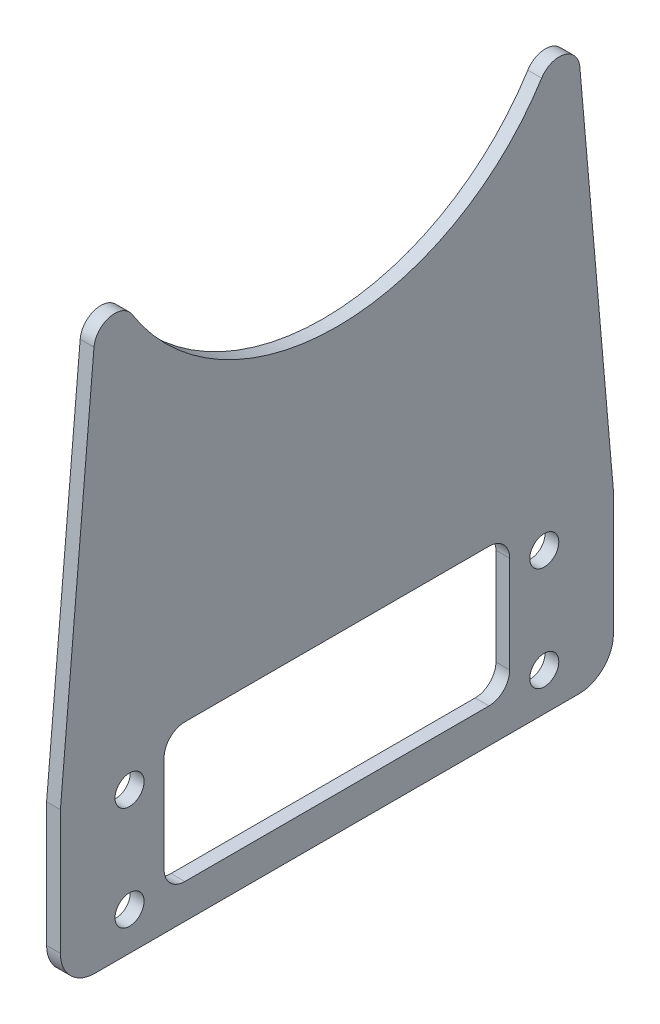
from build123d import *

# Parameters (mm, degrees)
EXTRUDE_1_DEPTH     = 2
SKETCH_2_R          = 2.1
SKETCH_2_W          = 50
SKETCH_2_H          = 20
CUT_EXTRUDE_1_DEPTH = 2
FILLET_1_R          = 3
FILLET_2_R          = 5


with BuildPart() as part:
    # 草图1 → 凸台-拉伸1 (new body)
    with BuildSketch(Plane(origin=(0, 0, 0), x_dir=(0, 0, -1), z_dir=(1, 0, 0))):
        with BuildLine():
            Line((-40, 11.5), (-34.088778562, 79.065570207))
            ThreePointArc((-34.088778562, 79.065570207), (0, 52), (34.088778562, 79.065570207))
            Line((34.088778562, 79.065570207), (40, 11.5))
            Line((40, 11.5), (40, -11.5))
            Line((40, -11.5), (-40, -11.5))
            Line((-40, -11.5), (-40, 11.5))
        make_face()
    extrude(amount=EXTRUDE_1_DEPTH)

    # 草图2 → 切除-拉伸1 (cut)
    with BuildSketch(Plane(origin=(2, 0, 0), x_dir=(0, 0, -1), z_dir=(1, 0, 0))):
        with Locations((-30, 9)):
            Circle(SKETCH_2_R)
        with Locations((-30, -6)):
            Circle(SKETCH_2_R)
        with Locations((30, -6)):
            Circle(SKETCH_2_R)
        with Locations((30, 9)):
            Circle(SKETCH_2_R)
        with Locations((0, 3.5)):
            Rectangle(SKETCH_2_W, SKETCH_2_H)
    extrude(amount=-CUT_EXTRUDE_1_DEPTH, mode=Mode.SUBTRACT)

    # 圆角1
    fillet_1_edges = [part.edges().sort_by_distance(p)[0] for p in [
        (1, 79.065570207, 34.088778562),
        (1, 79.065570207, -34.088778562),
        (1, 13.5, -25),
        (1, -6.5, -25),
        (1, -6.5, 25),
        (1, 13.5, 25),
    ]]
    fillet(fillet_1_edges, radius=FILLET_1_R)

    # 圆角2
    fillet_2_edges = [part.edges().sort_by_distance(p)[0] for p in [
        (1, -11.5, -40),
        (1, -11.5, 40),
    ]]
    fillet(fillet_2_edges, radius=FILLET_2_R)


solid = part.part
